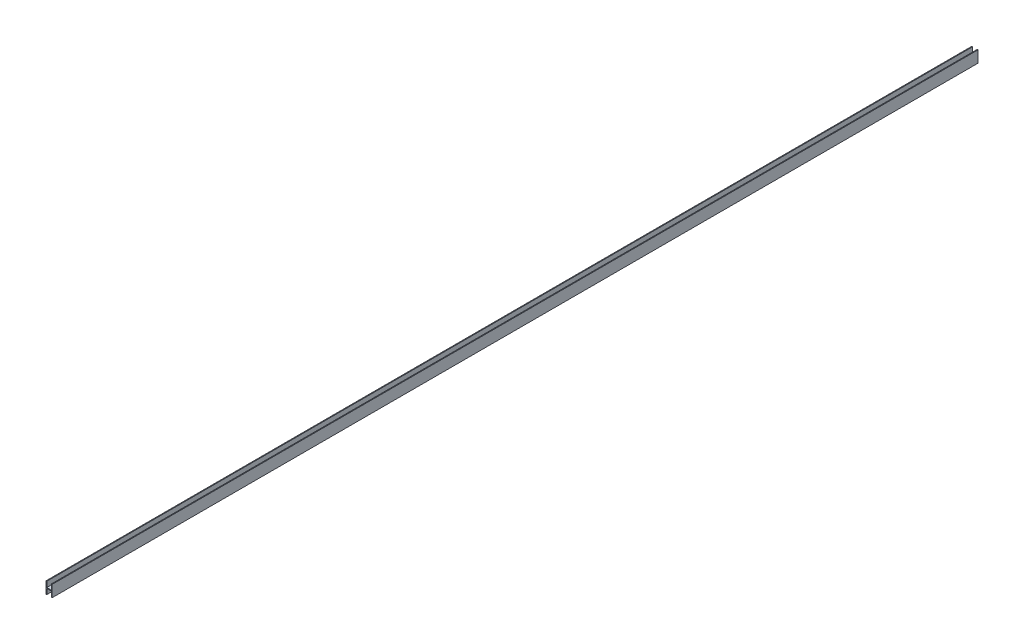
from build123d import *

# Parameters (mm, degrees)
SKETCH_1_W          = 8
SKETCH_1_H          = 15
EXTRUDE_1_DEPTH     = 1200
SKETCH_2_W          = 6
SKETCH_2_H          = 14
CUT_EXTRUDE_1_DEPTH = 2400


with BuildPart() as part:
    # 草图1 → 凸台-拉伸1 (new body)
    with BuildSketch(Plane.XY):
        Rectangle(SKETCH_1_W, SKETCH_1_H)
    extrude(amount=EXTRUDE_1_DEPTH)

    # 草图2 → 切除-拉伸1 (cut)
    with BuildSketch(Plane(origin=(0, 0, 0), x_dir=(-1, 0, 0), z_dir=(0, 0, -1))):
        with Locations((0, -7.5)):
            Rectangle(SKETCH_2_W, SKETCH_2_H)
        with Locations((0, 7.5)):
            Rectangle(SKETCH_2_W, SKETCH_2_H)
    extrude(amount=-CUT_EXTRUDE_1_DEPTH, mode=Mode.SUBTRACT)


solid = part.part
